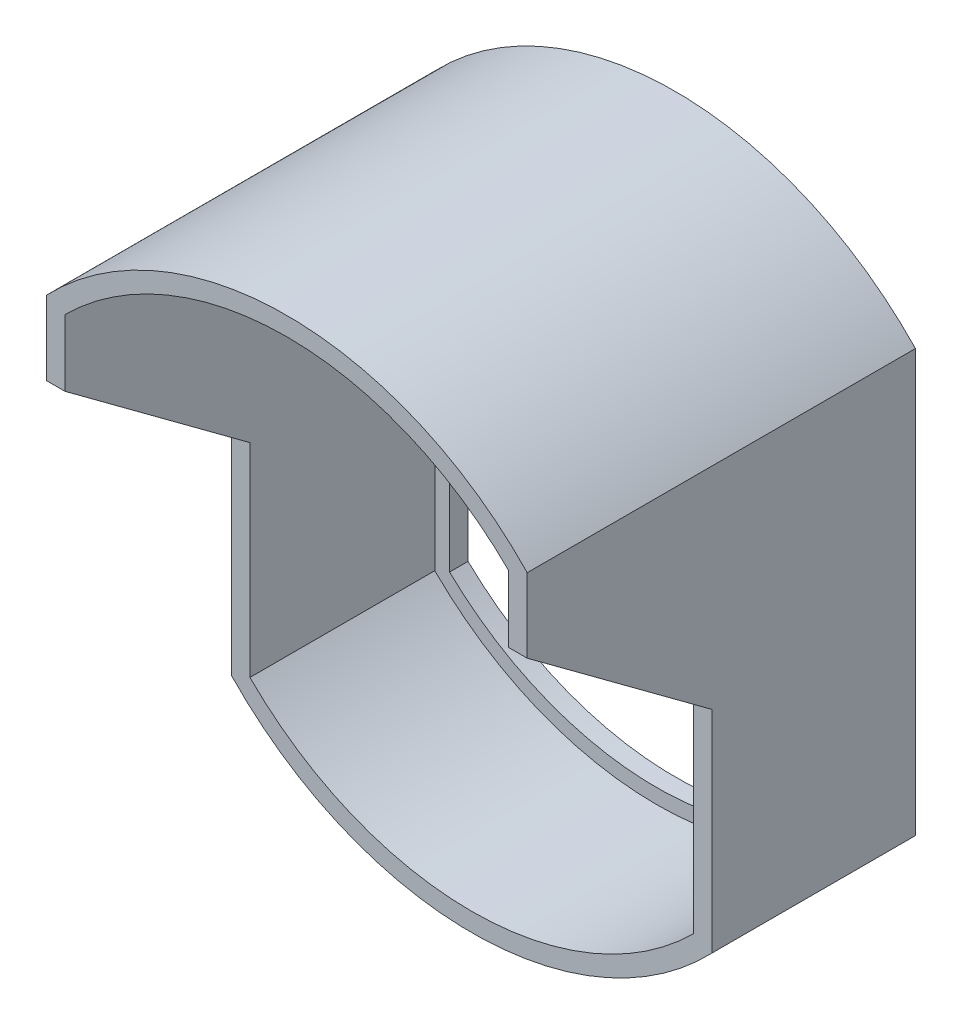
from build123d import *

# Parameters (mm, degrees)
ESBO_O1_W                = 95.625
ESBO_O1_H                = 63.75
RESSALTO_EXTRUS_O1_DEPTH = 50
RESSALTO_EXTRUS_O2_DEPTH = 100
CORTE_EXTRUS_O1_DEPTH    = 100
CORTE_EXTRUS_O2_DEPTH    = 169
RESSALTO_EXTRUS_O3_DEPTH = 5


with BuildPart() as part:
    # Esboço1 → Ressalto-extrusão1 (new body)
    with BuildSketch(Plane.XY):
        with BuildLine():
            Line((0, 0), (0, -110))
            ThreePointArc((0, -110), (60, -134.792027106), (120, -110))
            Line((120, -110), (120, 0))
            ThreePointArc((120, 0), (60, 24.792027106), (0, 0))
        make_face()
        with Locations((60, -55)):
            Rectangle(ESBO_O1_W, ESBO_O1_H, mode=Mode.SUBTRACT)
    extrude(amount=RESSALTO_EXTRUS_O1_DEPTH)

    # Esboço2 → Ressalto-extrusão2 (add)
    with BuildSketch(Plane(origin=(0, 0, 0), x_dir=(-1, 0, 0), z_dir=(0, 0, -1))):
        with BuildLine():
            Line((-125, 2.041525096), (-125, -112.041525096))
            ThreePointArc((-125, -112.041525096), (-60, -139.792027106), (5, -112.041525096))
            Line((5, -112.041525096), (5, 2.041525096))
            ThreePointArc((5, 2.041525096), (-60, 29.792027106), (-125, 2.041525096))
        make_face()
        with BuildLine():
            Line((0, 0), (0, -110))
            ThreePointArc((0, -110), (-60, -134.792027106), (-120, -110))
            Line((-120, -110), (-120, 0))
            ThreePointArc((-120, 0), (-60, 24.792027106), (0, 0))
        make_face(mode=Mode.SUBTRACT)
    extrude(amount=-RESSALTO_EXTRUS_O2_DEPTH)

    # Esboço3 → Corte-extrusão1 (cut)
    with BuildSketch(Plane.XY.offset(50)):
        with BuildLine():
            Line((0, 0), (0, -110))
            ThreePointArc((0, -110), (60, -134.792027106), (120, -110))
            Line((120, -110), (120, 0))
            ThreePointArc((120, 0), (60, 24.792027106), (0, 0))
        make_face()
    extrude(amount=-CORTE_EXTRUS_O1_DEPTH, mode=Mode.SUBTRACT)

    # Esboço4 → Corte-extrusão2 (cut)
    with BuildSketch(Plane(origin=(125, 0, 0), x_dir=(0, 0, -1), z_dir=(1, 0, 0))):
        Polygon((-50, -55), (-100, -17.994062777), (-100, -175.493521459), (-50, -175.493521459), align=None)
    extrude(amount=-CORTE_EXTRUS_O2_DEPTH, mode=Mode.SUBTRACT)

    # Esboço5 → Ressalto-extrusão3 (add)
    with BuildSketch(Plane(origin=(0, 0, 0), x_dir=(-1, 0, 0), z_dir=(0, 0, -1))):
        with BuildLine():
            Line((-125, 2.041525096), (-125, -112.041525096))
            ThreePointArc((-125, -112.041525096), (-60, -139.792027106), (5, -112.041525096))
            Line((5, -112.041525096), (5, 2.041525096))
            ThreePointArc((5, 2.041525096), (-60, 29.792027106), (-125, 2.041525096))
        make_face()
        with BuildLine():
            Line((-116, -1.68447334), (-116, -108.31552666))
            ThreePointArc((-116, -108.31552666), (-60, -130.792027106), (-4, -108.31552666))
            Line((-4, -108.31552666), (-4, -1.68447334))
            ThreePointArc((-4, -1.68447334), (-60, 20.792027106), (-116, -1.68447334))
        make_face(mode=Mode.SUBTRACT)
    extrude(amount=RESSALTO_EXTRUS_O3_DEPTH)


solid = part.part
